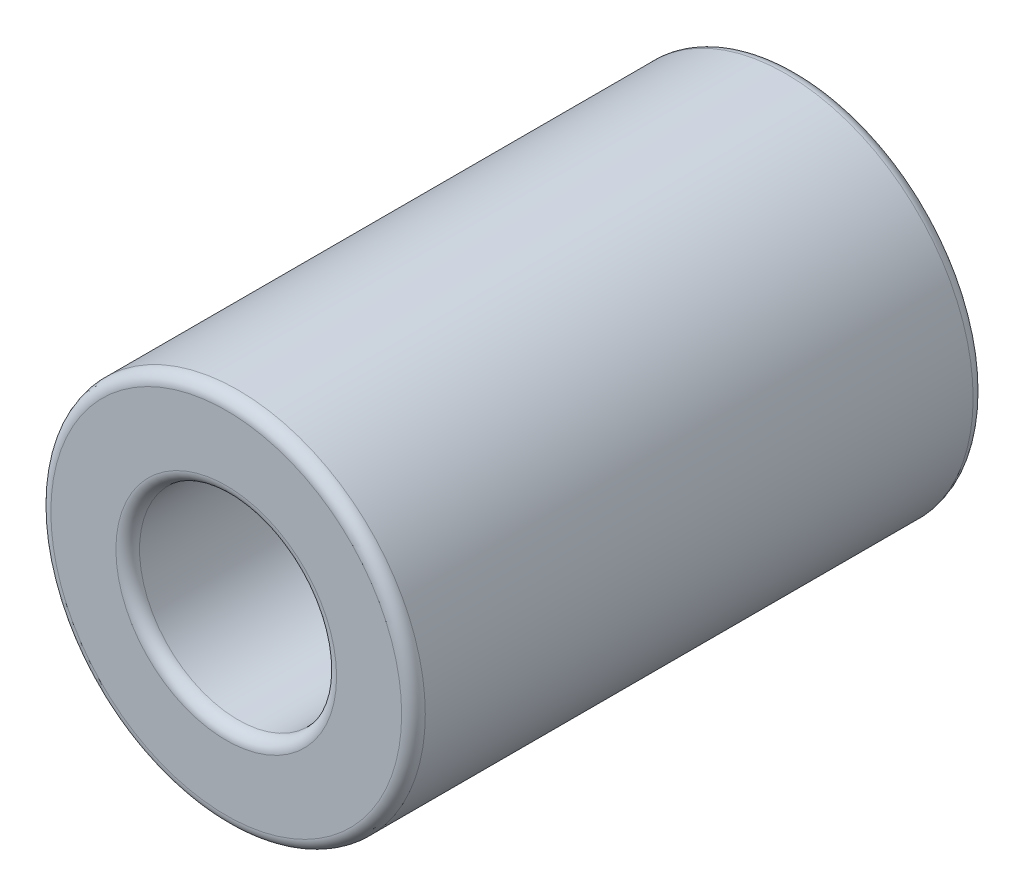
from build123d import *

# Parameters (mm, degrees)
ESQUISSE1_R        = 9.5
ESQUISSE1_R_2      = 5
BOSS_EXTRU_1_DEPTH = 29
CONG_1_R           = 0.6


with BuildPart() as part:
    # Esquisse1 → Boss.-Extru.1 (new body)
    with BuildSketch(Plane.XY):
        Circle(ESQUISSE1_R)
        Circle(ESQUISSE1_R_2, mode=Mode.SUBTRACT)
    extrude(amount=BOSS_EXTRU_1_DEPTH)

    # Congé1
    cong_1_edges = [part.edges().sort_by_distance(p)[0] for p in [
        (-9.5, 0, 0),
        (-9.5, 0, 29),
        (-5, 0, 0),
        (-5, 0, 29),
    ]]
    fillet(cong_1_edges, radius=CONG_1_R)


solid = part.part
